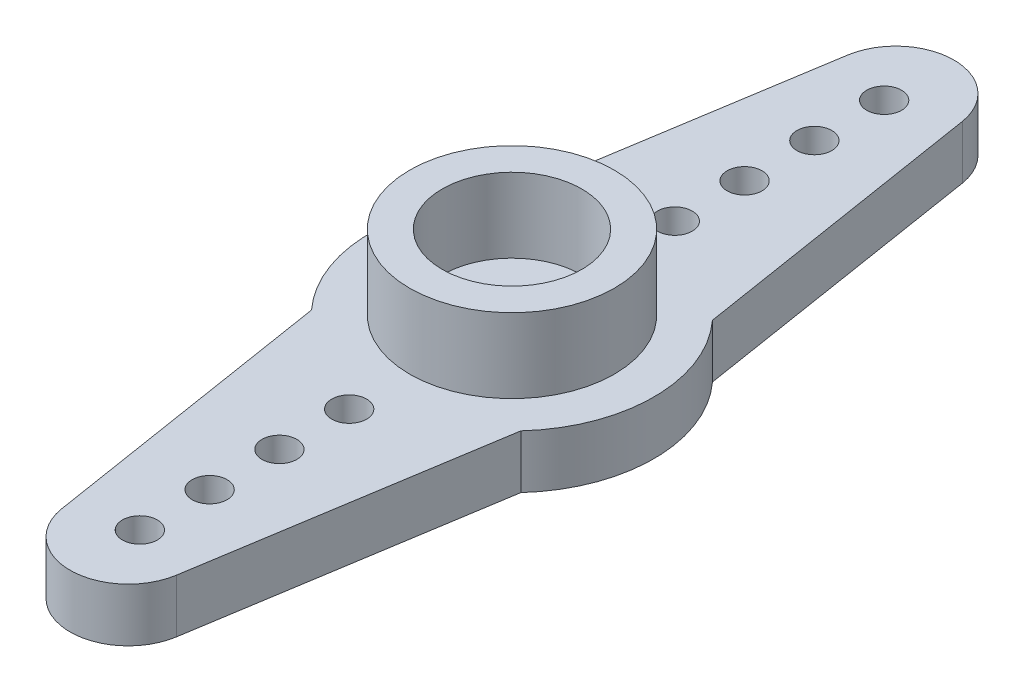
from build123d import *

# Parameters (mm, degrees)
SKETCH1_R           = 6.1
SKETCH1_R_2         = 1.5
BOSS_EXTRUDE1_DEPTH = 2.3
SKETCH2_R           = 4.4
SKETCH2_R_2         = 3
BOSS_EXTRUDE2_DEPTH = 3.2
SKETCH3_R           = 0.75
BOSS_EXTRUDE3_DEPTH = 2.3
CIRPATTERN1_COUNT   = 2


with BuildPart() as part:
    # Sketch1 → Boss-Extrude1 (new body)
    with BuildSketch(Plane(origin=(0, 0, 0), x_dir=(1, 0, 0), z_dir=(0, 1, 0))):
        Circle(SKETCH1_R)
        Circle(SKETCH1_R_2, mode=Mode.SUBTRACT)
    extrude(amount=BOSS_EXTRUDE1_DEPTH)

    # Sketch2 → Boss-Extrude2 (add)
    with BuildSketch(Plane(origin=(0, 2.3, 0), x_dir=(1, 0, 0), z_dir=(0, 1, 0))):
        Circle(SKETCH2_R)
        Circle(SKETCH2_R_2, mode=Mode.SUBTRACT)
    extrude(amount=BOSS_EXTRUDE2_DEPTH)

    # Sketch3 → Boss-Extrude3 (add)
    with BuildSketch(Plane.XZ):
        with BuildLine():
            Line((-4.5, -4.118252056), (-2.468988638, -16.892549493))
            ThreePointArc((-2.468988638, -16.892549493), (0, -19), (2.468988638, -16.892549493))
            Line((2.468988638, -16.892549493), (4.5, -4.118252056))
            ThreePointArc((4.5, -4.118252056), (0, -6.1), (-4.5, -4.118252056))
        make_face()
        with Locations((0, -16)):
            Circle(SKETCH3_R, mode=Mode.SUBTRACT)
        with Locations((0, -13)):
            Circle(SKETCH3_R, mode=Mode.SUBTRACT)
        with Locations((0, -10)):
            Circle(SKETCH3_R, mode=Mode.SUBTRACT)
        with Locations((0, -7)):
            Circle(SKETCH3_R, mode=Mode.SUBTRACT)
    boss_extrude3 = extrude(amount=-BOSS_EXTRUDE3_DEPTH)

    # CirPattern1: Boss-Extrude3 ×2 about axis
    cirpattern1_axis = Axis((0, 0, 0), (0, 1, 0))
    for i in range(1, CIRPATTERN1_COUNT):
        add(boss_extrude3.rotate(cirpattern1_axis, i * 360 / CIRPATTERN1_COUNT))


solid = part.part
